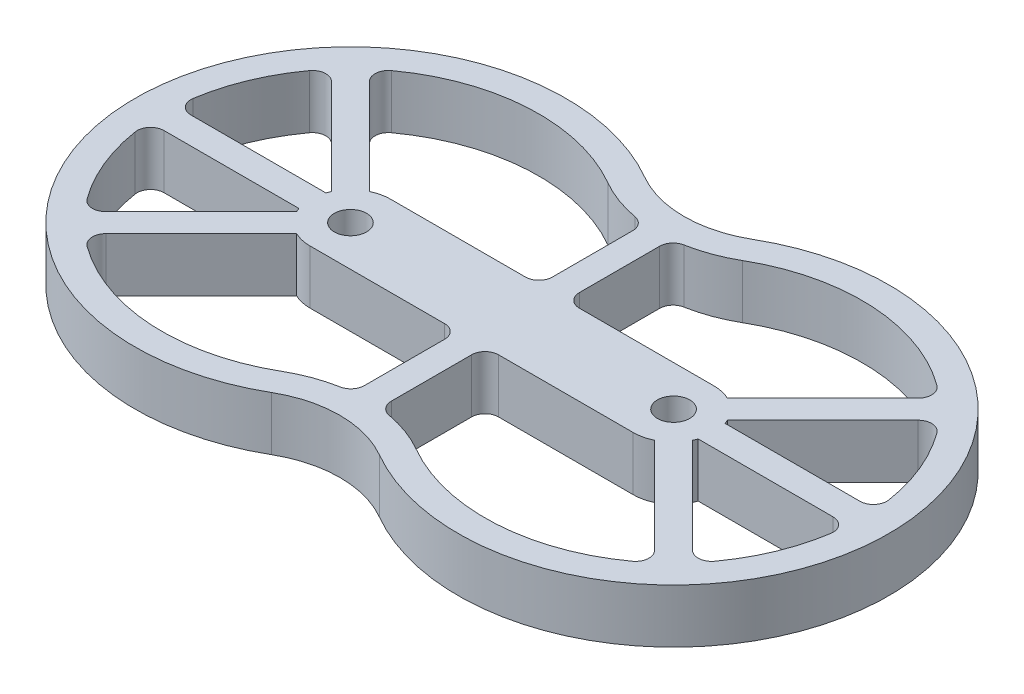
from build123d import *

# Parameters (mm, degrees)
SKETCH1_R           = 6
BOSS_EXTRUDE1_DEPTH = 20


with BuildPart() as part:
    # Sketch1 → Boss-Extrude1 (new body)
    with BuildSketch(Plane(origin=(0, 0, 0), x_dir=(1, 0, 0), z_dir=(0, 1, 0))):
        with BuildLine():
            ThreePointArc((40, 69.282032303), (-80, 0), (40, -69.282032303))
            ThreePointArc((40, -69.282032303), (60, -63.923048454), (80, -69.282032303))
            ThreePointArc((80, -69.282032303), (200, 0), (80, 69.282032303))
            ThreePointArc((80, 69.282032303), (60, 63.923048454), (40, 69.282032303))
        make_face()
        Circle(SKETCH1_R, mode=Mode.SUBTRACT)
        with Locations((120, 0)):
            Circle(SKETCH1_R, mode=Mode.SUBTRACT)
        with BuildLine():
            Line((55, 20), (55, 49.839779322))
            ThreePointArc((55, 49.839779322), (53.843530574, 53.037790068), (50.909090909, 54.756440152))
            ThreePointArc((50.909090909, 54.756440152), (42.704102554, 57.009810114), (35, 60.621778265))
            ThreePointArc((35, 60.621778265), (-3.755089291, 69.899208182), (-41.293201923, 56.523194133))
            ThreePointArc((-41.293201923, 56.523194133), (-43.328783805, 52.871588373), (-41.879221406, 48.950289217))
            Line((-41.879221406, 48.950289217), (-6.464466094, 13.535533906))
            ThreePointArc((-6.464466094, 13.535533906), (-3.31413574, 14.629302933), (0, 15))
            Line((0, 15), (50, 15))
            ThreePointArc((50, 15), (53.535533906, 16.464466094), (55, 20))
        make_face(mode=Mode.SUBTRACT)
        with BuildLine():
            Line((0, -15), (50, -15))
            ThreePointArc((50, -15), (53.535533906, -16.464466094), (55, -20))
            Line((55, -20), (55, -49.839779322))
            ThreePointArc((55, -49.839779322), (53.843530574, -53.037790068), (50.909090909, -54.756440152))
            ThreePointArc((50.909090909, -54.756440152), (42.704102554, -57.009810114), (35, -60.621778265))
            ThreePointArc((35, -60.621778265), (-3.755089291, -69.899208182), (-41.293201923, -56.523194133))
            ThreePointArc((-41.293201923, -56.523194133), (-43.328783805, -52.871588373), (-41.879221406, -48.950289217))
            Line((-41.879221406, -48.950289217), (-6.464466094, -13.535533906))
            ThreePointArc((-6.464466094, -13.535533906), (-3.31413574, -14.629302933), (0, -15))
        make_face(mode=Mode.SUBTRACT)
        with BuildLine():
            Line((65, 20), (65, 49.839779322))
            ThreePointArc((65, 49.839779322), (66.156469426, 53.037790068), (69.090909091, 54.756440152))
            ThreePointArc((69.090909091, 54.756440152), (77.295897446, 57.009810114), (85, 60.621778265))
            ThreePointArc((85, 60.621778265), (123.755089291, 69.899208182), (161.293201923, 56.523194133))
            ThreePointArc((161.293201923, 56.523194133), (163.328783805, 52.871588373), (161.879221406, 48.950289217))
            Line((161.879221406, 48.950289217), (126.464466094, 13.535533906))
            ThreePointArc((126.464466094, 13.535533906), (123.31413574, 14.629302933), (120, 15))
            Line((120, 15), (70, 15))
            ThreePointArc((70, 15), (66.464466094, 16.464466094), (65, 20))
        make_face(mode=Mode.SUBTRACT)
        with BuildLine():
            Line((65, -20), (65, -49.839779322))
            ThreePointArc((65, -49.839779322), (66.156469426, -53.037790068), (69.090909091, -54.756440152))
            ThreePointArc((69.090909091, -54.756440152), (77.295897446, -57.009810114), (85, -60.621778265))
            ThreePointArc((85, -60.621778265), (123.755089291, -69.899208182), (161.293201923, -56.523194133))
            ThreePointArc((161.293201923, -56.523194133), (163.328783805, -52.871588373), (161.879221406, -48.950289217))
            Line((161.879221406, -48.950289217), (126.464466094, -13.535533906))
            ThreePointArc((126.464466094, -13.535533906), (123.31413574, -14.629302933), (120, -15))
            Line((120, -15), (70, -15))
            ThreePointArc((70, -15), (66.464466094, -16.464466094), (65, -20))
        make_face(mode=Mode.SUBTRACT)
        with BuildLine():
            Line((134.142135624, 5), (184.226162893, 5))
            ThreePointArc((184.226162893, 5), (188.02393552, 6.747781822), (189.166636962, 10.769230769))
            ThreePointArc((189.166636962, 10.769230769), (184.671567276, 26.787840266), (176.523194133, 41.293201923))
            ThreePointArc((176.523194133, 41.293201923), (172.871588373, 43.328783805), (168.950289217, 41.879221406))
            Line((168.950289217, 41.879221406), (133.535533906, 6.464466094))
            ThreePointArc((133.535533906, 6.464466094), (133.858192988, 5.740251485), (134.142135624, 5))
        make_face(mode=Mode.SUBTRACT)
        with BuildLine():
            Line((134.142135624, -5), (184.226162893, -5))
            ThreePointArc((184.226162893, -5), (188.02393552, -6.747781822), (189.166636962, -10.769230769))
            ThreePointArc((189.166636962, -10.769230769), (184.671567276, -26.787840266), (176.523194133, -41.293201923))
            ThreePointArc((176.523194133, -41.293201923), (172.871588373, -43.328783805), (168.950289217, -41.879221406))
            Line((168.950289217, -41.879221406), (133.535533906, -6.464466094))
            ThreePointArc((133.535533906, -6.464466094), (133.858192988, -5.740251485), (134.142135624, -5))
        make_face(mode=Mode.SUBTRACT)
        with BuildLine():
            Line((-13.535533906, 6.464466094), (-48.950289217, 41.879221406))
            ThreePointArc((-48.950289217, 41.879221406), (-52.871588373, 43.328783805), (-56.523194133, 41.293201923))
            ThreePointArc((-56.523194133, 41.293201923), (-64.671567276, 26.787840266), (-69.166636962, 10.769230769))
            ThreePointArc((-69.166636962, 10.769230769), (-68.02393552, 6.747781822), (-64.226162893, 5))
            Line((-64.226162893, 5), (-14.142135624, 5))
            ThreePointArc((-14.142135624, 5), (-13.858192988, 5.740251485), (-13.535533906, 6.464466094))
        make_face(mode=Mode.SUBTRACT)
        with BuildLine():
            Line((-14.142135624, -5), (-64.226162893, -5))
            ThreePointArc((-64.226162893, -5), (-68.02393552, -6.747781822), (-69.166636962, -10.769230769))
            ThreePointArc((-69.166636962, -10.769230769), (-64.671567276, -26.787840266), (-56.523194133, -41.293201923))
            ThreePointArc((-56.523194133, -41.293201923), (-52.871588373, -43.328783805), (-48.950289217, -41.879221406))
            Line((-48.950289217, -41.879221406), (-13.535533906, -6.464466094))
            ThreePointArc((-13.535533906, -6.464466094), (-13.858192988, -5.740251485), (-14.142135624, -5))
        make_face(mode=Mode.SUBTRACT)
    extrude(amount=BOSS_EXTRUDE1_DEPTH)


solid = part.part
